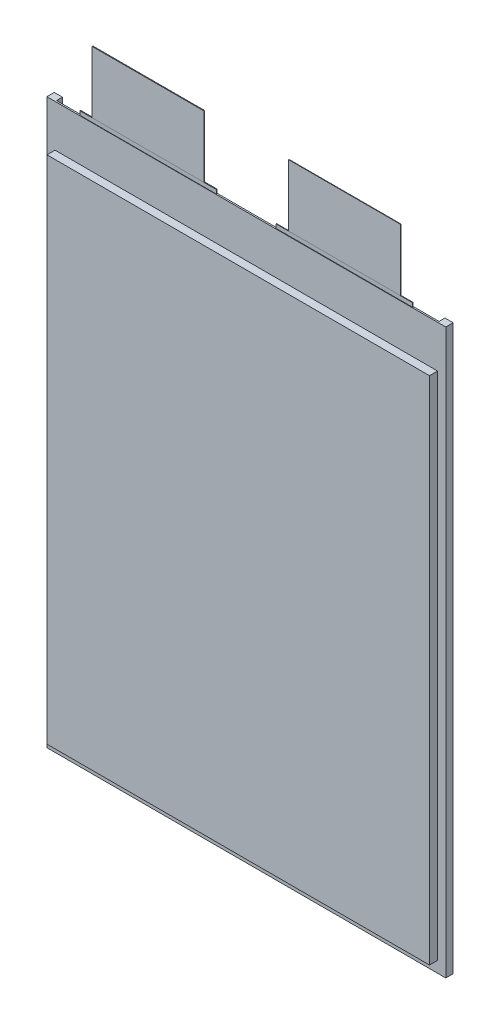
from build123d import *

# Parameters (mm, degrees)
SKETCH1_W                    = 160.6
SKETCH1_H                    = 227
INSULATION_DEPTH             = 0.3
INSULATION_DEPTH_BACK        = 0.3
SKETCH2_W                    = 154
SKETCH2_H                    = 205.5
MAIN_BODY_DEPTH              = 3.55
MAIN_BODY_DEPTH_BACK         = 3.55
SIDE_FOLDS_DEPTH             = 2.366666667
SKETCH6_W                    = 55
SKETCH6_H                    = 18.6
NEGATIVE_TAB_BASE_DEPTH      = 0.1
NEGATIVE_TAB_BASE_DEPTH_BACK = 0.1
SKETCH7_W                    = 55
SKETCH7_H                    = 18.6
POSITIVE_TAB_BASE_DEPTH      = 0.15
POSITIVE_TAB_BASE_DEPTH_BACK = 0.15
SKETCH113_W                  = 0.2
SKETCH113_H                  = 45
NEGATIVE_TAB_DEPTH           = 24.9
SKETCH110_W                  = 0.3
SKETCH110_H                  = 45
POSITIVE_TAB_DEPTH           = 24.9


with BuildPart() as part:
    # Sketch1 → Insulation (new, two sides)
    with BuildSketch(Plane.XY) as insulation_sk:
        Rectangle(SKETCH1_W, SKETCH1_H)
    extrude(amount=INSULATION_DEPTH)
    extrude(insulation_sk.sketch, amount=-INSULATION_DEPTH_BACK)

    # Sketch2 → Main Body (add, two sides)
    with BuildSketch(Plane.XY) as main_body_sk:
        with Locations((0, -6.25)):
            Rectangle(SKETCH2_W, SKETCH2_H)
    extrude(amount=MAIN_BODY_DEPTH)
    extrude(main_body_sk.sketch, amount=-MAIN_BODY_DEPTH_BACK)

    # Sketch5 → Side Folds (add)
    with BuildSketch(Plane(origin=(0, 0, -0.3), x_dir=(-1, 0, 0), z_dir=(0, 0, -1))):
        Polygon((-77, -109), (-77, 96.5), (-77, 113.5), (-80.3, 113.5), (-80.3, -113.5), (-77, -113.5), align=None)
        Polygon((77, 113.5), (77, 96.5), (77, -109), (77, -113.5), (80.3, -113.5), (80.3, 113.5), align=None)
    extrude(amount=SIDE_FOLDS_DEPTH)

    # Sketch6 → Negative Tab Base (add, two sides)
    with BuildSketch(Plane.XY) as negative_tab_base_sk:
        with Locations((39.3, 105.8)):
            Rectangle(SKETCH6_W, SKETCH6_H)
    extrude(amount=NEGATIVE_TAB_BASE_DEPTH)
    extrude(negative_tab_base_sk.sketch, amount=-NEGATIVE_TAB_BASE_DEPTH_BACK)

    # Sketch7 → Positive Tab Base (add, two sides)
    with BuildSketch(Plane.XY) as positive_tab_base_sk:
        with Locations((-39.7, 105.8)):
            Rectangle(SKETCH7_W, SKETCH7_H)
    extrude(amount=POSITIVE_TAB_BASE_DEPTH)
    extrude(positive_tab_base_sk.sketch, amount=-POSITIVE_TAB_BASE_DEPTH_BACK)


with BuildPart() as body_2:
    # Sketch113 → Negative Tab (new body)
    with BuildSketch(Plane(origin=(39.3, 115.1, 0), x_dir=(0, 0, -1), z_dir=(0, 1, 0))):
        Rectangle(SKETCH113_W, SKETCH113_H)
    extrude(amount=NEGATIVE_TAB_DEPTH)


with BuildPart() as body_3:
    # Sketch110 → Positive Tab (new body)
    with BuildSketch(Plane(origin=(-39.7, 115.1, 0), x_dir=(0, 0, -1), z_dir=(0, 1, 0))):
        Rectangle(SKETCH110_W, SKETCH110_H)
    extrude(amount=POSITIVE_TAB_DEPTH)


solid = Compound([part.part, body_2.part, body_3.part])
